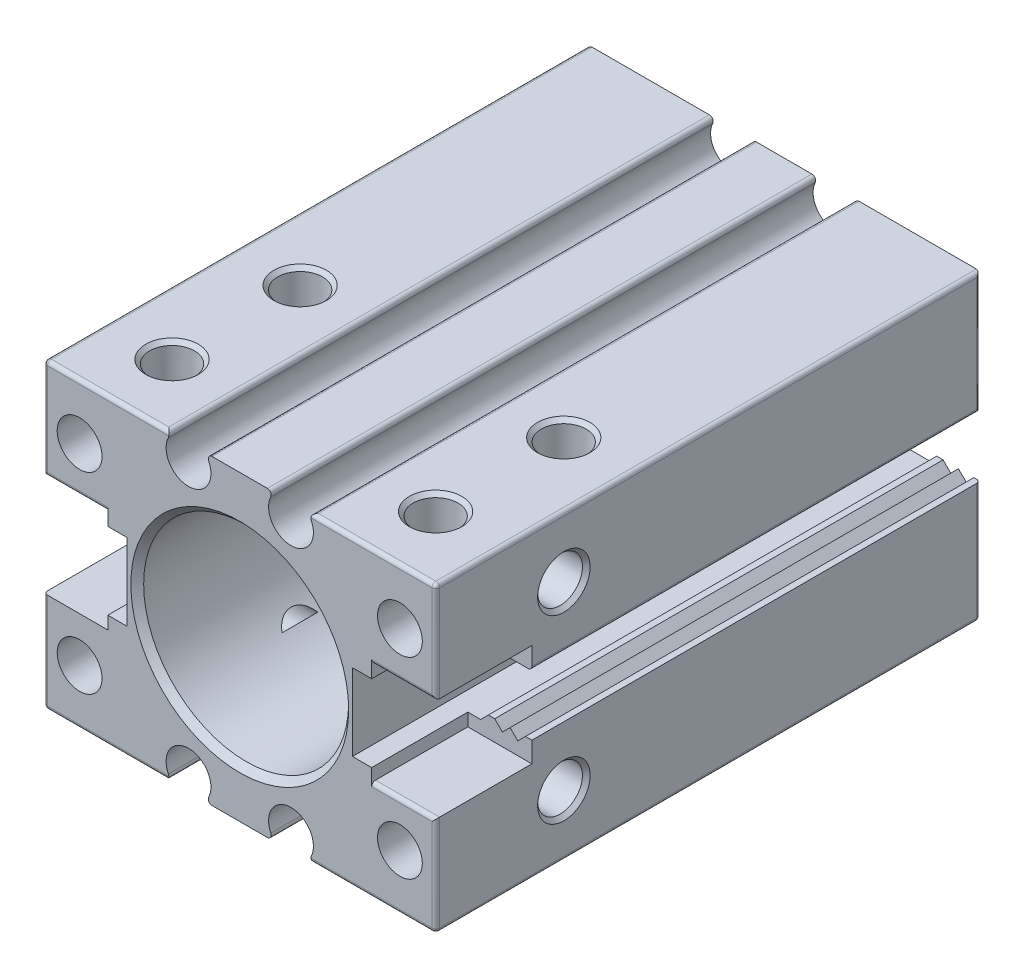
from build123d import *

# Parameters (mm, degrees)
SKETCH1_W               = 30.6
SKETCH1_H               = 23.6
BOSS_EXTRUDE1_DEPTH     = 42.5
SKETCH2_R               = 1.75
CUT_EXTRUDE1_DEPTH      = 1
CUT_EXTRUDE1_DEPTH_BACK = 43.5
SKETCH3_R               = 8
CUT_EXTRUDE2_DEPTH      = 43.5
SKETCH4_R               = 0.6
BOSS_EXTRUDE2_DEPTH     = 0.5
SKETCH5_R               = 8
BOSS_EXTRUDE3_DEPTH     = 1
SKETCH7_R               = 1.75
CUT_EXTRUDE3_DEPTH      = 8
SKETCH8_R               = 1.75
CUT_EXTRUDE4_DEPTH      = 5
SKETCH9_W               = 14.215744851
SKETCH9_H               = 8
CUT_EXTRUDE5_DEPTH      = 5
SKETCH10_R              = 1.75
CUT_EXTRUDE6_DEPTH      = 10
CHAMFER1_SIZE           = 0.5
FILLET1_R               = 0.3
MIRROR5_COPY_1_SKETCH_R = 1.75
MIRROR5_COPY_1_DEPTH    = 5
CHAMFER2_SIZE           = 0.3
SKETCH12_R              = 1.75
BOSS_EXTRUDE4_DEPTH     = 20
SKETCH13_R              = 2
CUT_EXTRUDE7_DEPTH      = 15


with BuildPart() as part:
    # Sketch1 → Boss-Extrude1 (new body)
    with BuildSketch(Plane.XY):
        Rectangle(SKETCH1_W, SKETCH1_H)
    extrude(amount=BOSS_EXTRUDE1_DEPTH)

    # Sketch2 → Cut-Extrude1 (cut, two sides)
    with BuildSketch(Plane(origin=(0, 0, 0), x_dir=(-1, 0, 0), z_dir=(0, 0, -1))) as cut_extrude1_sk:
        with Locations((-4, -10.6)):
            Circle(SKETCH2_R)
        with Locations((4, -10.6)):
            Circle(SKETCH2_R)
        with Locations((4, 10.6)):
            Circle(SKETCH2_R)
        with Locations((-4, 10.6)):
            Circle(SKETCH2_R)
        Polygon((-8.8, -3), (-8.8, 3), (-12.4, 3), (-13, 2.3), (-15.3, 2.3), (-15.3, -2.4), (-14.8, -2.4), (-14.2, -3), (-13.6, -2.4), (-13, -3), (-12.4, -2.4), (-11.9, -2.4), (-11.3, -3), align=None)
        Polygon((13, 2.3), (15.3, 2.3), (15.3, -2.3), (13, -2.3), (12.4, -3), (8.8, -3), (8.8, 3), (12.4, 3), align=None)
    extrude(amount=CUT_EXTRUDE1_DEPTH, mode=Mode.SUBTRACT)
    extrude(cut_extrude1_sk.sketch, amount=-CUT_EXTRUDE1_DEPTH_BACK, mode=Mode.SUBTRACT)

    # Sketch3 → Cut-Extrude2 (cut, through all)
    with BuildSketch(Plane(origin=(0, 0, 0), x_dir=(-1, 0, 0), z_dir=(0, 0, -1))):
        Circle(SKETCH3_R)
    extrude(amount=-CUT_EXTRUDE2_DEPTH, mode=Mode.SUBTRACT)

    # Sketch4 → Boss-Extrude2 (add)
    with BuildSketch(Plane(origin=(0, 0, 5), x_dir=(-1, 0, 0), z_dir=(0, 0, -1))):
        with BuildLine():
            Line((-7.553115235, 2.636370657), (-6.353739267, 2.335958795))
            ThreePointArc((-6.353739267, 2.335958795), (-5.083132329, 2.806119669), (-5.060463857, 4.160733776))
            ThreePointArc((-5.060463857, 4.160733776), (-5.15676506, 4.549428174), (-4.987070016, 4.912141351))
            ThreePointArc((-4.987070016, 4.912141351), (7, 0), (-4.987070016, -4.912141351))
            ThreePointArc((-4.987070016, -4.912141351), (-5.15676506, -4.549428174), (-5.060463857, -4.160733776))
            ThreePointArc((-5.060463857, -4.160733776), (-5.083132329, -2.806119669), (-6.353739267, -2.335958795))
            Line((-6.353739267, -2.335958795), (-7.553115235, -2.636370657))
            ThreePointArc((-7.553115235, -2.636370657), (8, 0), (-7.553115235, 2.636370657))
        make_face()
        with Locations((-6.062177826, 3.5)):
            Circle(SKETCH4_R, mode=Mode.SUBTRACT)
        with Locations((-6.062177826, -3.5)):
            Circle(SKETCH4_R, mode=Mode.SUBTRACT)
    extrude(amount=BOSS_EXTRUDE2_DEPTH)

    # Sketch5 → Boss-Extrude3 (add)
    with BuildSketch(Plane(origin=(0, 0, 5), x_dir=(-1, 0, 0), z_dir=(0, 0, -1))):
        Circle(SKETCH5_R)
    extrude(amount=-BOSS_EXTRUDE3_DEPTH)

    # Sketch7 → Cut-Extrude3 (cut)
    with BuildSketch(Plane(origin=(0, 0, 0), x_dir=(-1, 0, 0), z_dir=(0, 0, -1))):
        with Locations((-12.5, 7.5)):
            Circle(SKETCH7_R)
        with Locations((12.5, 7.5)):
            Circle(SKETCH7_R)
        with Locations((12.5, -7.5)):
            Circle(SKETCH7_R)
        with Locations((-12.5, -7.5)):
            Circle(SKETCH7_R)
    cut_extrude3 = extrude(amount=-CUT_EXTRUDE3_DEPTH, mode=Mode.SUBTRACT)

    # Sketch8 → Cut-Extrude4 (cut)
    with BuildSketch(Plane(origin=(0, 11.8, 0), x_dir=(1, 0, 0), z_dir=(0, 1, 0))):
        with Locations((-10.28688696, -37.5)):
            Circle(SKETCH8_R)
        with Locations((-10.28688696, -27.5)):
            Circle(SKETCH8_R)
    cut_extrude4 = extrude(amount=-CUT_EXTRUDE4_DEPTH, mode=Mode.SUBTRACT)

    # Mirror1: Cut-Extrude4 across plane
    add(cut_extrude4.mirror(Plane.ZX), mode=Mode.SUBTRACT)

    # Sketch9 → Cut-Extrude5 (cut)
    with BuildSketch(Plane.ZY.offset(15.3)):
        with Locations((42.107872426, 0)):
            Rectangle(SKETCH9_W, SKETCH9_H)
    cut_extrude5 = extrude(amount=-CUT_EXTRUDE5_DEPTH, mode=Mode.SUBTRACT)

    # Mirror2: Cut-Extrude5 across plane
    add(cut_extrude5.mirror(Plane(origin=(0, 0, 0), x_dir=(0, 0, 1), z_dir=(1, 0, 0))), mode=Mode.SUBTRACT)

    # Sketch10 → Cut-Extrude6 (cut)
    with BuildSketch(Plane.ZY.offset(15.3)):
        with Locations((32.5, 7.05)):
            Circle(SKETCH10_R)
        with Locations((32.5, -7.05)):
            Circle(SKETCH10_R)
    cut_extrude6 = extrude(amount=-CUT_EXTRUDE6_DEPTH, mode=Mode.SUBTRACT)

    # Chamfer1
    chamfer1_edges = [part.edges().sort_by_distance(p)[0] for p in [
        (8, 0, 42.5),
        (8, 0, 0),
    ]]
    chamfer(chamfer1_edges, length=CHAMFER1_SIZE)

    # Fillet1
    fillet1_edges = [part.edges().sort_by_distance(p)[0] for p in [
        (12.8, -4, 42.5),
        (15.3, -7.9, 42.5),
        (10.28688696, -11.8, 42.5),
        (-10.28688696, -11.8, 42.5),
        (-10.28688696, 11.8, 42.5),
        (-12.8, 4, 42.5),
        (12.8, 4, 42.5),
        (15.3, 7.9, 42.5),
        (10.28688696, 11.8, 42.5),
        (-10.28688696, -11.8, 0),
        (10.28688696, -11.8, 0),
        (15.3, -7.1, 0),
        (15.3, 7.05, 0),
        (-15.3, 7.9, 42.5),
        (-15.3, 7.05, 0),
        (-15.3, -7.05, 0),
        (-15.3, -7.9, 42.5),
        (-13, -2.3, 17.5),
        (-13, 2.3, 17.5),
        (13, 2.3, 17.5),
        (15.3, 2.3, 17.5),
        (-15.3, 2.3, 17.5),
        (-15.3, -2.3, 17.5),
        (-15.3, -11.8, 21.25),
        (15.3, -11.8, 21.25),
        (15.3, 11.8, 21.25),
        (-15.3, 11.8, 21.25),
        (2.72622608, -11.8, 21.25),
        (5.27377392, -11.8, 21.25),
        (-2.72622608, -11.8, 21.25),
        (-5.27377392, -11.8, 21.25),
        (2.72622608, 11.8, 21.25),
        (5.27377392, 11.8, 21.25),
        (-2.72622608, 11.8, 21.25),
        (-5.27377392, 11.8, 21.25),
    ]]
    fillet(fillet1_edges, radius=FILLET1_R)

    # Mirror4: Cut-Extrude3 across plane
    add(cut_extrude3.mirror(Plane.XY.offset(21.25)), mode=Mode.SUBTRACT)

    # Mirror5: Cut-Extrude4, Cut-Extrude6 across plane
    add(cut_extrude4.mirror(Plane(origin=(0, 0, 0), x_dir=(0, 0, 1), z_dir=(1, 0, 0))), mode=Mode.SUBTRACT)
    add(cut_extrude6.mirror(Plane(origin=(0, 0, 0), x_dir=(0, 0, 1), z_dir=(1, 0, 0))), mode=Mode.SUBTRACT)

    # Mirror5 copy 1 sketch → Mirror5 copy 1 (cut)
    with BuildSketch(Plane(origin=(0, -11.8, 0), x_dir=(-1, 0, 0), z_dir=(0, -1, 0))):
        with Locations((-10.28688696, -37.5)):
            Circle(MIRROR5_COPY_1_SKETCH_R)
        with Locations((-10.28688696, -27.5)):
            Circle(MIRROR5_COPY_1_SKETCH_R)
    extrude(amount=-MIRROR5_COPY_1_DEPTH, mode=Mode.SUBTRACT)

    # Chamfer2
    chamfer2_edges = [part.edges().sort_by_distance(p)[0] for p in [
        (-12.03688696, 11.8, 37.5),
        (-12.03688696, 11.8, 27.5),
        (-12.03688696, -11.8, 37.5),
        (-12.03688696, -11.8, 27.5),
        (-15.3, 7.05, 30.75),
        (-15.3, -7.05, 30.75),
        (12.03688696, 11.8, 37.5),
        (12.03688696, 11.8, 27.5),
        (12.03688696, -11.8, 37.5),
        (12.03688696, -11.8, 27.5),
        (15.3, 7.05, 30.75),
        (15.3, -7.05, 30.75),
    ]]
    chamfer(chamfer2_edges, length=CHAMFER2_SIZE)

    # Sketch12 → Boss-Extrude4 (add)
    with BuildSketch(Plane(origin=(0, 0, 0), x_dir=(-1, 0, 0), z_dir=(0, 0, -1))):
        with Locations((-12.5, 7.5)):
            Circle(SKETCH12_R)
        with Locations((12.5, 7.5)):
            Circle(SKETCH12_R)
        with Locations((12.5, -7.5)):
            Circle(SKETCH12_R)
        with Locations((-12.5, -7.5)):
            Circle(SKETCH12_R)
    extrude(amount=-BOSS_EXTRUDE4_DEPTH)

    # Sketch13 → Cut-Extrude7 (cut)
    with BuildSketch(Plane(origin=(0, 0, 0), x_dir=(-1, 0, 0), z_dir=(0, 0, -1))):
        with Locations((-11, 7.65)):
            Circle(SKETCH13_R)
        with Locations((11, 7.65)):
            Circle(SKETCH13_R)
        with Locations((11, -7.35)):
            Circle(SKETCH13_R)
        with Locations((-11, -7.35)):
            Circle(SKETCH13_R)
    extrude(amount=-CUT_EXTRUDE7_DEPTH, mode=Mode.SUBTRACT)


solid = part.part
